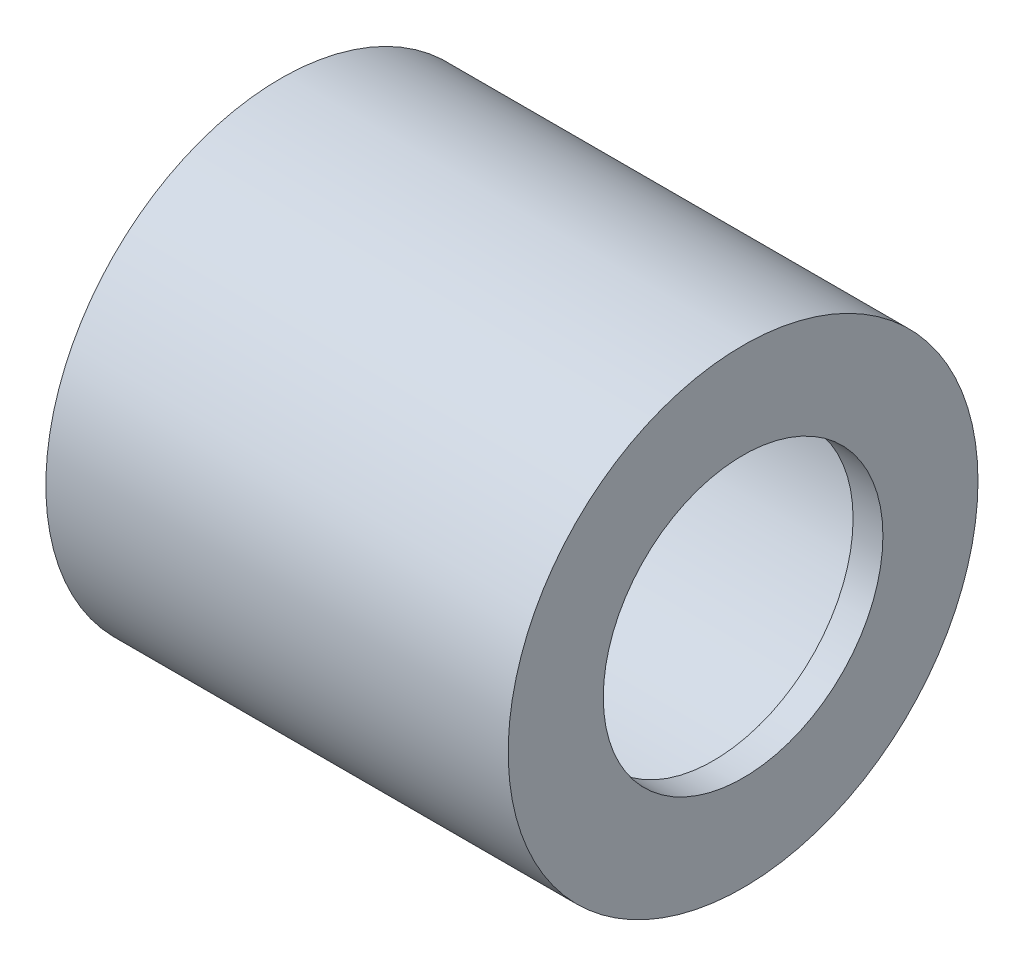
from build123d import *

# Parameters (mm, degrees)
SKETCH1_R          = 4.0005
EXTRUDE1_DEPTH     = 7.874
SKETCH2_R          = 3.603625
CUT_EXTRUDE1_DEPTH = 7.366
SKETCH3_R          = 2.38125
CUT_EXTRUDE2_DEPTH = 1.508


with BuildPart() as part:
    # Sketch1 → Extrude1 (new body)
    with BuildSketch(Plane(origin=(0, 0, 0), x_dir=(0, 0, -1), z_dir=(1, 0, 0))):
        Circle(SKETCH1_R)
    extrude(amount=EXTRUDE1_DEPTH)

    # Sketch2 → Cut-Extrude1 (cut)
    with BuildSketch(Plane.ZY):
        Circle(SKETCH2_R)
    extrude(amount=-CUT_EXTRUDE1_DEPTH, mode=Mode.SUBTRACT)

    # Sketch3 → Cut-Extrude2 (cut, through all)
    with BuildSketch(Plane.ZY.offset(-7.366)):
        Circle(SKETCH3_R)
    extrude(amount=-CUT_EXTRUDE2_DEPTH, mode=Mode.SUBTRACT)


solid = part.part
